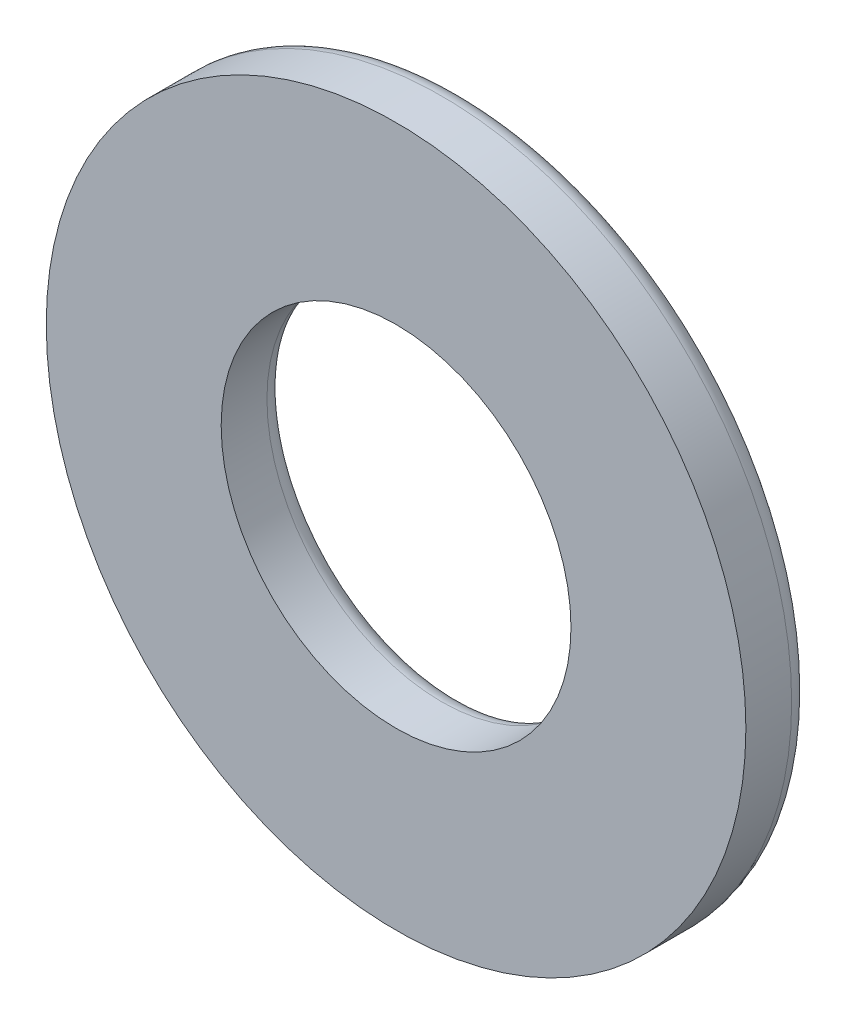
from build123d import *

# Parameters (mm, degrees)
SKETCH1_R           = 13.589
SKETCH1_R_2         = 6.7945
BOSS_EXTRUDE1_DEPTH = 2.54
FILLET1_R           = 0.762


with BuildPart() as part:
    # Sketch1 → Boss-Extrude1 (new body)
    with BuildSketch(Plane.XY):
        Circle(SKETCH1_R)
        Circle(SKETCH1_R_2, mode=Mode.SUBTRACT)
    extrude(amount=BOSS_EXTRUDE1_DEPTH)

    # Fillet1
    fillet1_edges = [part.edges().sort_by_distance(p)[0] for p in [
        (-13.589, 0, 0),
        (-6.7945, 0, 0),
    ]]
    fillet(fillet1_edges, radius=FILLET1_R)


solid = part.part
